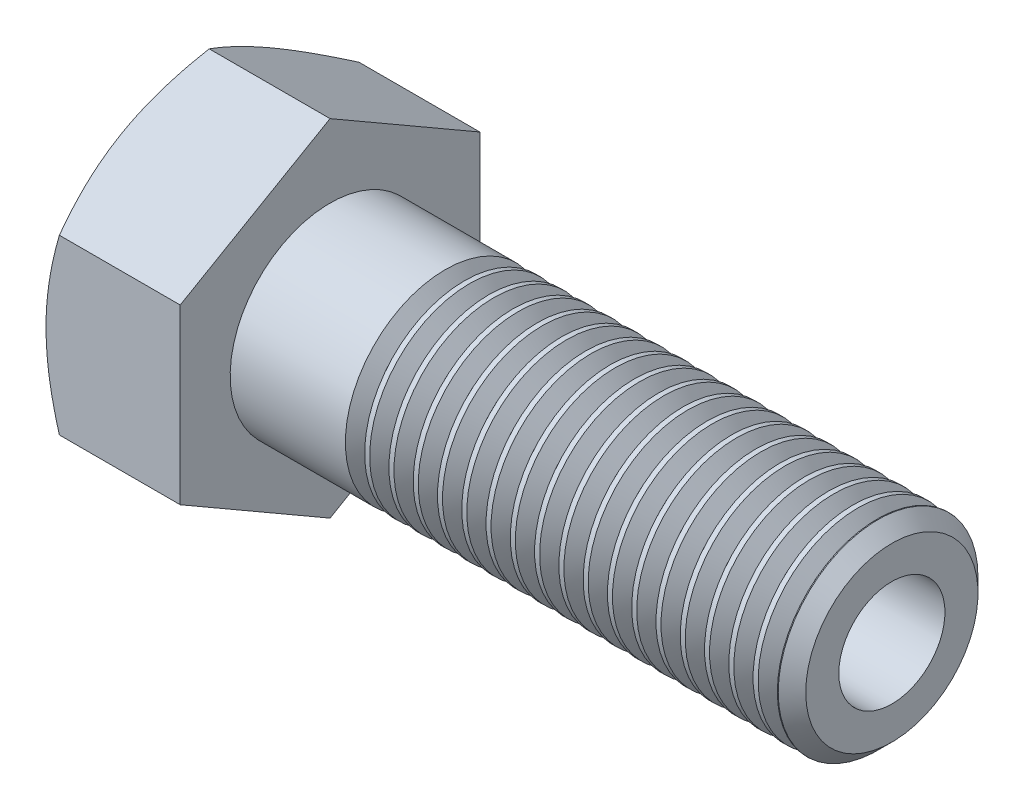
from build123d import *

# Parameters (mm, degrees)
BASEHEAD_DEPTH     = 10.75
THDSCHPAT_COUNT    = 18
THDSCHPAT_PITCH    = 1.944444444
SKETCH4_R          = 4.25
CUT_EXTRUDE1_DEPTH = 56.75


with BuildPart() as part:
    # Sketch1 → BaseHead (new body)
    with BuildSketch(Plane(origin=(0, 0, 0), x_dir=(0, 0, -1), z_dir=(1, 0, 0))):
        Polygon((12, 6.92820323), (12, -6.92820323), (0, -13.856406461), (-12, -6.92820323), (-12, 6.92820323), (0, 13.856406461), align=None)
    extrude(amount=BASEHEAD_DEPTH)

    # BodySke → BaseBody (revolve)
    with BuildSketch(Plane.XY):
        Polygon((0, 0), (55.75, 0), (55.75, 6.8985), (54.6485, 8), (0, 8), align=None)
    revolve(axis=Axis((0, 0, 0), (1, 0, 0)))

    # Sketch3 → HeadChamfer (revolve, cut)
    with BuildSketch(Plane.XY):
        Polygon((0, 12), (3.958548116, 18.856406461), (3.958548116, 23.856406461), (-10, 23.856406461), (-10, 12), align=None)
    revolve(axis=Axis((0, 0, 0), (1, 0, 0)), mode=Mode.SUBTRACT)

    # ThdSchSke → ThreadSchematic (revolve, cut)
    with BuildSketch(Plane.XY):
        Polygon((20.75, -6.8985), (19.978721397, -8), (19.978721397, -10), (21.521278603, -10), (21.521278603, -8), align=None)
    threadschematic = revolve(axis=Axis((-3.175, 0, 0), (1, 0, 0)), mode=Mode.SUBTRACT)

    # ThdSchPat: ThreadSchematic ×18
    with Locations(*[(i * THDSCHPAT_PITCH, 0, 0) for i in range(1, THDSCHPAT_COUNT)]):
        add(threadschematic, mode=Mode.SUBTRACT)

    # Sketch4 → Cut-Extrude1 (cut, through all)
    with BuildSketch(Plane.ZY):
        Circle(SKETCH4_R)
    extrude(amount=-CUT_EXTRUDE1_DEPTH, mode=Mode.SUBTRACT)


solid = part.part
